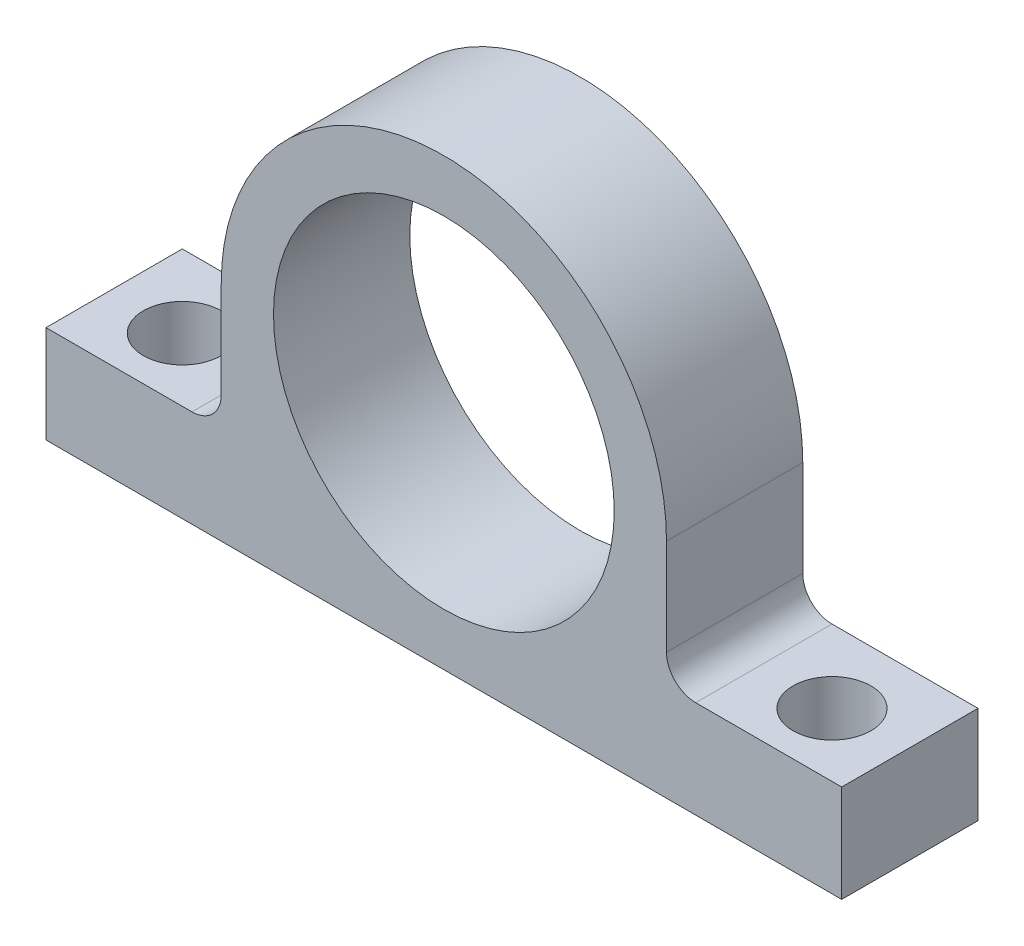
from build123d import *

# Parameters (mm, degrees)
SKETCH1_R           = 17.5
BOSS_EXTRUDE1_DEPTH = 14
SKETCH2_R           = 4
CUT_EXTRUDE1_DEPTH  = 11


with BuildPart() as part:
    # Sketch1 → Boss-Extrude1 (new body)
    with BuildSketch(Plane.XY):
        with BuildLine():
            Line((40.87, -22.87), (-40.87, -22.87))
            Line((-40.87, -22.87), (-40.87, -12.87))
            Line((-40.87, -12.87), (-25.87, -12.87))
            ThreePointArc((-25.87, -12.87), (-23.748679656, -11.991320344), (-22.87, -9.87))
            Line((-22.87, -9.87), (-22.87, 0))
            ThreePointArc((-22.87, 0), (0, 22.87), (22.87, 0))
            Line((22.87, 0), (22.87, -9.87))
            ThreePointArc((22.87, -9.87), (23.748679656, -11.991320344), (25.87, -12.87))
            Line((25.87, -12.87), (40.87, -12.87))
            Line((40.87, -12.87), (40.87, -22.87))
        make_face()
        Circle(SKETCH1_R, mode=Mode.SUBTRACT)
    extrude(amount=BOSS_EXTRUDE1_DEPTH)

    # Sketch2 → Cut-Extrude1 (cut, through all)
    with BuildSketch(Plane(origin=(0, -12.87, 0), x_dir=(1, 0, 0), z_dir=(0, 1, 0))):
        with Locations((33.37, -7.5)):
            Circle(SKETCH2_R)
    cut_extrude1 = extrude(amount=-CUT_EXTRUDE1_DEPTH, mode=Mode.SUBTRACT)

    # Mirror1: Cut-Extrude1 across plane
    add(cut_extrude1.mirror(Plane(origin=(0, 0, 0), x_dir=(0, 0, 1), z_dir=(1, 0, 0))), mode=Mode.SUBTRACT)


solid = part.part
